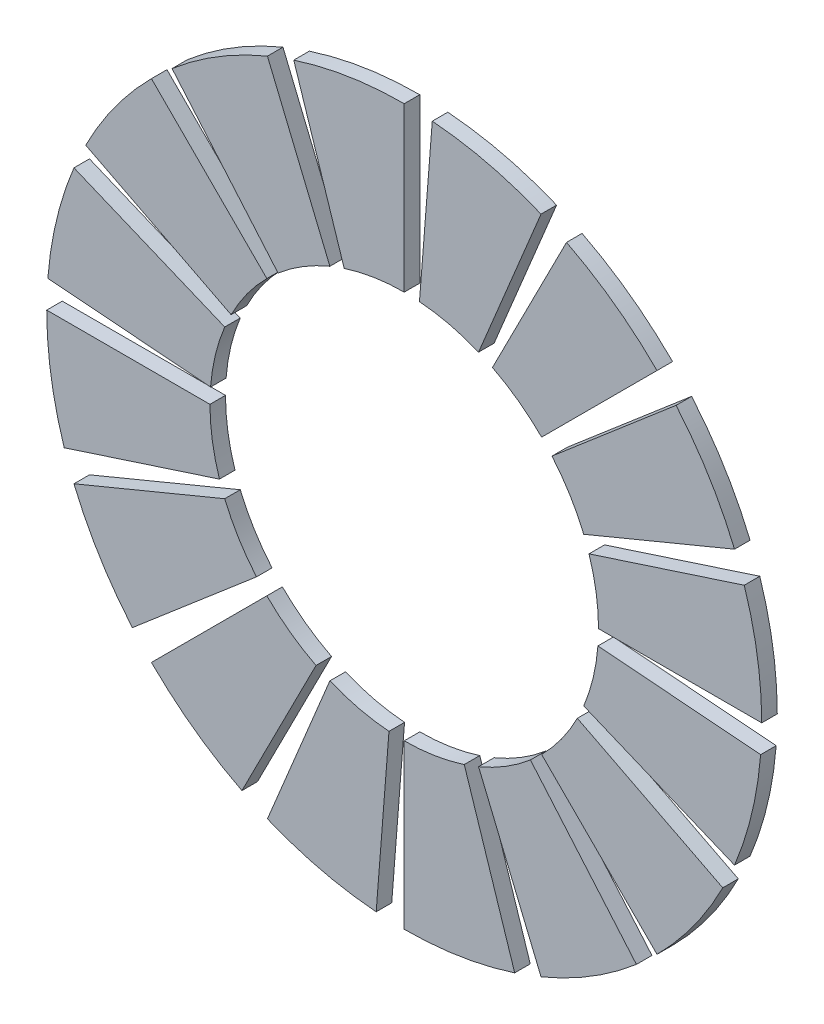
from build123d import *

# Parameters (mm, degrees)
BOSS_EXTRUDE2_DEPTH = 2
CIRPATTERN12_COUNT  = 16


with BuildPart() as part:
    # Sketch2 → Boss-Extrude2 (new body)
    with BuildSketch(Plane.XY):
        with BuildLine():
            Line((25, 0), (46, 0))
            ThreePointArc((46, 0), (45.433663667, 7.195985392), (43.74859975, 14.214781741))
            Line((43.74859975, 14.214781741), (23.776412907, 7.725424859))
            ThreePointArc((23.776412907, 7.725424859), (24.692208515, 3.910861626), (25, 0))
        make_face()
    extrude(amount=BOSS_EXTRUDE2_DEPTH)


with BuildPart() as cirpattern12_1:
    # CirPattern12: pattern copy
    add(part.part.rotate(Axis((0, 0, 0), (0, 0, 1)), 1 * 360 / CIRPATTERN12_COUNT))


with BuildPart() as cirpattern12_2:
    # CirPattern12: pattern copy
    add(part.part.rotate(Axis((0, 0, 0), (0, 0, 1)), 2 * 360 / CIRPATTERN12_COUNT))


with BuildPart() as cirpattern12_3:
    # CirPattern12: pattern copy
    add(part.part.rotate(Axis((0, 0, 0), (0, 0, 1)), 3 * 360 / CIRPATTERN12_COUNT))


with BuildPart() as cirpattern12_4:
    # CirPattern12: pattern copy
    add(part.part.rotate(Axis((0, 0, 0), (0, 0, 1)), 4 * 360 / CIRPATTERN12_COUNT))


with BuildPart() as cirpattern12_5:
    # CirPattern12: pattern copy
    add(part.part.rotate(Axis((0, 0, 0), (0, 0, 1)), 5 * 360 / CIRPATTERN12_COUNT))


with BuildPart() as cirpattern12_6:
    # CirPattern12: pattern copy
    add(part.part.rotate(Axis((0, 0, 0), (0, 0, 1)), 6 * 360 / CIRPATTERN12_COUNT))


with BuildPart() as cirpattern12_7:
    # CirPattern12: pattern copy
    add(part.part.rotate(Axis((0, 0, 0), (0, 0, 1)), 7 * 360 / CIRPATTERN12_COUNT))


with BuildPart() as cirpattern12_8:
    # CirPattern12: pattern copy
    add(part.part.rotate(Axis((0, 0, 0), (0, 0, 1)), 8 * 360 / CIRPATTERN12_COUNT))


with BuildPart() as cirpattern12_9:
    # CirPattern12: pattern copy
    add(part.part.rotate(Axis((0, 0, 0), (0, 0, 1)), 9 * 360 / CIRPATTERN12_COUNT))


with BuildPart() as cirpattern12_10:
    # CirPattern12: pattern copy
    add(part.part.rotate(Axis((0, 0, 0), (0, 0, 1)), 10 * 360 / CIRPATTERN12_COUNT))


with BuildPart() as cirpattern12_11:
    # CirPattern12: pattern copy
    add(part.part.rotate(Axis((0, 0, 0), (0, 0, 1)), 11 * 360 / CIRPATTERN12_COUNT))


with BuildPart() as cirpattern12_12:
    # CirPattern12: pattern copy
    add(part.part.rotate(Axis((0, 0, 0), (0, 0, 1)), 12 * 360 / CIRPATTERN12_COUNT))


with BuildPart() as cirpattern12_13:
    # CirPattern12: pattern copy
    add(part.part.rotate(Axis((0, 0, 0), (0, 0, 1)), 13 * 360 / CIRPATTERN12_COUNT))


with BuildPart() as cirpattern12_14:
    # CirPattern12: pattern copy
    add(part.part.rotate(Axis((0, 0, 0), (0, 0, 1)), 14 * 360 / CIRPATTERN12_COUNT))


with BuildPart() as cirpattern12_15:
    # CirPattern12: pattern copy
    add(part.part.rotate(Axis((0, 0, 0), (0, 0, 1)), 15 * 360 / CIRPATTERN12_COUNT))


solid = Compound([part.part, cirpattern12_1.part, cirpattern12_2.part, cirpattern12_3.part, cirpattern12_4.part, cirpattern12_5.part, cirpattern12_6.part, cirpattern12_7.part, cirpattern12_8.part, cirpattern12_9.part, cirpattern12_10.part, cirpattern12_11.part, cirpattern12_12.part, cirpattern12_13.part, cirpattern12_14.part, cirpattern12_15.part])
